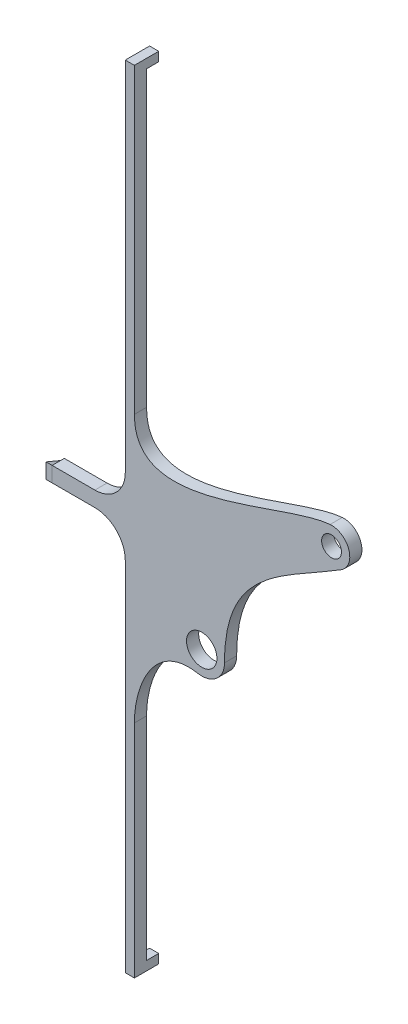
from build123d import *

# Parameters (mm, degrees)
MAIN_FEATURES_SKETCH_R   = 3.2639
MAIN_FEATURES_SKETCH_R_2 = 5
MAIN_BODY_DEPTH          = 4
SKETCH1_3_W              = 3
SKETCH1_3_H              = 3
ALIGNMENT_TABS_DEPTH     = 4
ARROW_DEPTH              = 2
FILLET1_R                = 10


with BuildPart() as part:
    # main_features_sketch → main_body (new body)
    with BuildSketch(Plane.XY):
        with BuildLine():
            Line((5, -130), (5, -57.340148315))
            add(Edge.make_bspline(
                [(25.812302368, -32.779740175), (11.779287511, -30.236028568), (5, -45.738607792), (5, -57.340148315)],
                knots=[0, 0, 0, 0, 1, 1, 1, 1], degree=3))
            ThreePointArc((25.812302368, -32.779740175), (31.960860099, -31.153748787), (34.649993747, -25.390314881))
            add(Edge.make_bspline(
                [(73.022366869, 20.307251386), (54.015932593, 8.467793569), (34.613495749, 2.873121555), (34.649993747, -25.390314881)],
                knots=[0, 0, 0, 0, 1, 1, 1, 1], degree=3))
            ThreePointArc((73.022366869, 20.307251386), (75.546863703, 27.283014592), (69.36238197, 31.380152896))
            add(Edge.make_bspline(
                [(5, 30.570880007), (5, 2.644791948), (53.27872464, 30.068701259), (69.36238197, 31.380152896)],
                knots=[0, 0, 0, 0, 1, 1, 1, 1], degree=3))
            Line((5, 30.570880007), (5, 130))
            Line((5, 130), (2, 130))
            Line((2, 130), (2, 2.5))
            Line((2, 2.5), (-22.05, 2.5))
            Line((-22.05, 2.5), (-22.05, -2.5))
            Line((-22.05, -2.5), (2, -2.5))
            Line((2, -2.5), (2, -130))
            Line((2, -130), (5, -130))
        make_face()
        with Locations((69.85, 25.4)):
            Circle(MAIN_FEATURES_SKETCH_R, mode=Mode.SUBTRACT)
        with Locations((27.15, -25.4)):
            Circle(MAIN_FEATURES_SKETCH_R_2, mode=Mode.SUBTRACT)
    extrude(amount=MAIN_BODY_DEPTH)

    # Sketch1_3 → alignment_tabs (add)
    with BuildSketch(Plane.XY):
        with Locations((3.5, -128.5)):
            Rectangle(SKETCH1_3_W, SKETCH1_3_H)
        with Locations((3.5, 128.5)):
            Rectangle(SKETCH1_3_W, SKETCH1_3_H)
    extrude(amount=-ALIGNMENT_TABS_DEPTH)

    # Fillet1
    fillet1_edges = [part.edges().sort_by_distance(p)[0] for p in [
        (2, 2.5, 2),
        (2, -2.5, 2),
    ]]
    fillet(fillet1_edges, radius=FILLET1_R)


with BuildPart() as body_2:
    # arrow_sketch → arrow (new body)
    with BuildSketch(Plane.ZY.offset(22.05)):
        Polygon((4, -2.5), (-2, 0), (4, 2.5), align=None)
    extrude(amount=ARROW_DEPTH)


solid = Compound([part.part, body_2.part])
